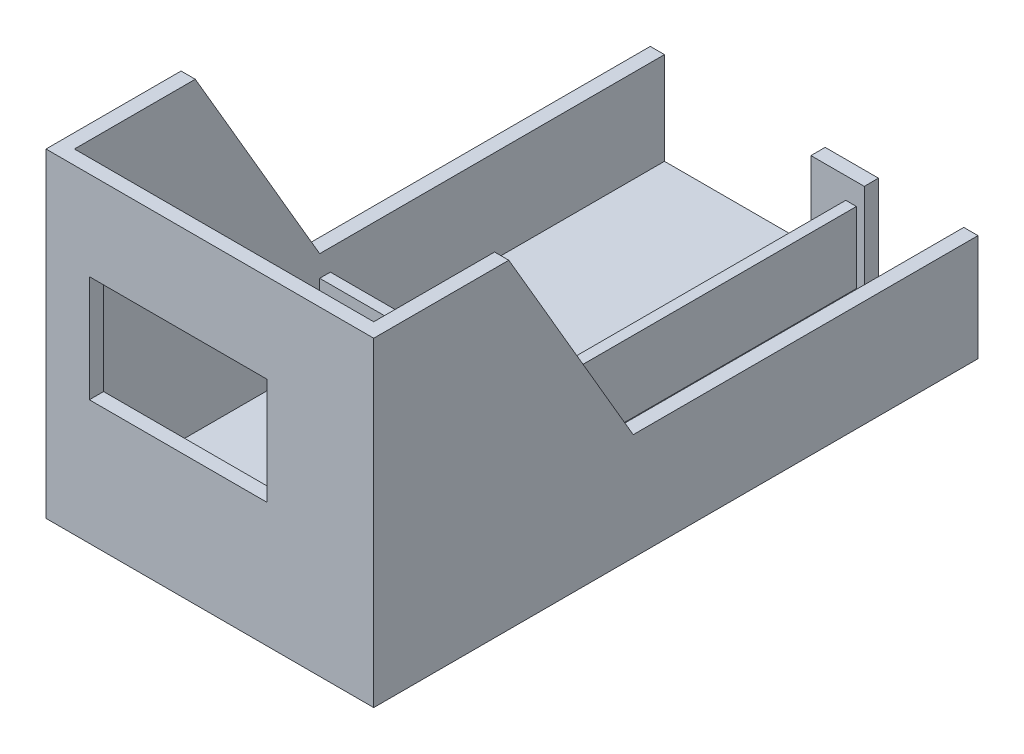
from build123d import *

# Parameters (mm, degrees)
SKETCH1_W           = 92.2
SKETCH1_H           = 170
BOX_DEPTH           = 90
SKETCH2_W           = 84.2
SKETCH2_H           = 162
BOX_CUT_DEPTH       = 86
BOSS_EXTRUDE2_DEPTH = 20
SKETCH4_W           = 24
SKETCH4_H           = 82
SKETCH4_W_2         = 45.2
SKETCH4_H_2         = 30
CUT_EXTRUDE2_DEPTH  = 4
SKETCH5_W           = 40
SKETCH5_H           = 20
CUT_EXTRUDE3_DEPTH  = 104
SKETCH6_W           = 50
SKETCH6_H           = 30
CUT_EXTRUDE4_DEPTH  = 14
SKETCH7_W           = 92.2
SKETCH7_H           = 97
CUT_EXTRUDE5_DEPTH  = 60
CUT_EXTRUDE6_DEPTH  = 100


with BuildPart() as part:
    # Sketch1 → Box (new body)
    with BuildSketch(Plane(origin=(0, 0, 0), x_dir=(1, 0, 0), z_dir=(0, 1, 0))):
        Rectangle(SKETCH1_W, SKETCH1_H)
    extrude(amount=BOX_DEPTH)

    # Sketch2 → Box Cut (cut)
    with BuildSketch(Plane(origin=(0, 90, 0), x_dir=(1, 0, 0), z_dir=(0, 1, 0))):
        Rectangle(SKETCH2_W, SKETCH2_H)
    extrude(amount=-BOX_CUT_DEPTH, mode=Mode.SUBTRACT)

    # Inside Walls → Boss-Extrude2 (add)
    with BuildSketch(Plane(origin=(0, 4, 0), x_dir=(1, 0, 0), z_dir=(0, 1, 0))):
        Polygon((-42.1, -9), (-42.1, -12), (16.1, -12), (16.1, -81), (19.1, -81), (19.1, -9), (15.9, -9), (15.9, 81), (12.9, 81), (12.9, -9), align=None)
    extrude(amount=BOSS_EXTRUDE2_DEPTH)

    # Sketch4 → Cut-Extrude2 (cut)
    with BuildSketch(Plane(origin=(0, 0, -85), x_dir=(-1, 0, 0), z_dir=(0, 0, -1))):
        with Locations((-30.1, 45)):
            Rectangle(SKETCH4_W, SKETCH4_H)
        with Locations((19.5, 19)):
            Rectangle(SKETCH4_W_2, SKETCH4_H_2)
    extrude(amount=-CUT_EXTRUDE2_DEPTH, mode=Mode.SUBTRACT)

    # Sketch5 → Cut-Extrude3 (cut)
    with BuildSketch(Plane.ZY.offset(46.1)):
        with Locations((-49.995549612, 50)):
            Rectangle(SKETCH5_W, SKETCH5_H)
    extrude(amount=-CUT_EXTRUDE3_DEPTH, mode=Mode.SUBTRACT)

    # Sketch6 → Cut-Extrude4 (cut)
    with BuildSketch(Plane.XY.offset(85)):
        with Locations((-8.9, 50)):
            Rectangle(SKETCH6_W, SKETCH6_H)
    extrude(amount=-CUT_EXTRUDE4_DEPTH, mode=Mode.SUBTRACT)

    # Sketch7 → Cut-Extrude5 (cut)
    with BuildSketch(Plane(origin=(0, 90, 0), x_dir=(1, 0, 0), z_dir=(0, 1, 0))):
        with Locations((0, 36.5)):
            Rectangle(SKETCH7_W, SKETCH7_H)
    extrude(amount=-CUT_EXTRUDE5_DEPTH, mode=Mode.SUBTRACT)

    # Sketch8 → Cut-Extrude6 (cut)
    with BuildSketch(Plane(origin=(46.1, 0, 0), x_dir=(0, 0, -1), z_dir=(1, 0, 0))):
        Polygon((-12, 30), (-47, 90), (-12, 90), align=None)
    extrude(amount=-CUT_EXTRUDE6_DEPTH, mode=Mode.SUBTRACT)


solid = part.part
